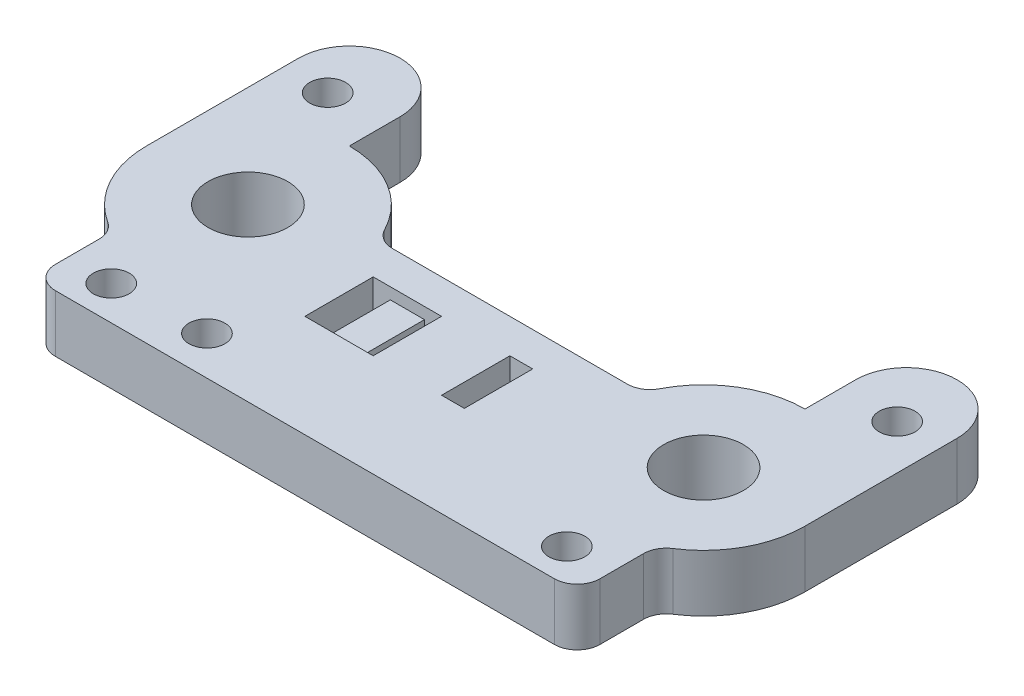
from build123d import *

# Parameters (mm, degrees)
BOSS_EXTRUDE1_DEPTH = 6.35
SKETCH3_R           = 4.445
CUT_EXTRUDE2_DEPTH  = 6.35
SKETCH11_W          = 2.54
SKETCH11_H          = 7.62
SKETCH11_W_2        = 1.905
CUT_EXTRUDE6_DEPTH  = 6.35
SKETCH14_W          = 3.81
SKETCH14_H          = 7.62
CUT_EXTRUDE8_DEPTH  = 1.27
SKETCH8_R           = 2
CUT_EXTRUDE10_DEPTH = 6.35
SKETCH15_R          = 2
CUT_EXTRUDE11_DEPTH = 6.35


with BuildPart() as part:
    # Sketch1 → Boss-Extrude1 (new body)
    with BuildSketch(Plane(origin=(0, 0, 0), x_dir=(1, 0, 0), z_dir=(0, 1, 0))):
        with BuildLine():
            Line((-25.4, 11.309999986), (-25.4, 16.964999979))
            ThreePointArc((-25.4, 16.964999979), (-31.054999993, 22.619999972), (-36.709999986, 16.964999979))
            Line((-36.709999986, 16.964999979), (-36.709999986, 11.309999986))
            Line((-36.709999986, 11.309999986), (-36.709999986, 0))
            ThreePointArc((-36.709999986, 0), (-35.329369206, -5.415138673), (-31.524548724, -9.508207119))
            ThreePointArc((-31.524548724, -9.508207119), (-30.670062071, -10.427428504), (-30.359999986, -11.643560444))
            Line((-30.359999986, -11.643560444), (-30.359999986, -16.51))
            ThreePointArc((-30.359999986, -16.51), (-29.61605121, -18.306051224), (-27.819999986, -19.05))
            Line((-27.819999986, -19.05), (27.819999986, -19.05))
            ThreePointArc((27.819999986, -19.05), (29.61605121, -18.306051224), (30.359999986, -16.51))
            Line((30.359999986, -16.51), (30.359999986, -11.643560444))
            ThreePointArc((30.359999986, -11.643560444), (30.670062071, -10.427428504), (31.524548724, -9.508207119))
            ThreePointArc((31.524548724, -9.508207119), (35.329369206, -5.415138673), (36.709999986, 0))
            Line((36.709999986, 0), (36.709999986, 11.309999986))
            Line((36.709999986, 11.309999986), (36.709999986, 16.964999979))
            ThreePointArc((36.709999986, 16.964999979), (31.054999993, 22.619999972), (25.4, 16.964999979))
            Line((25.4, 16.964999979), (25.4, 11.309999986))
            ThreePointArc((25.4, 11.309999986), (20.457539197, 10.172914081), (16.508889627, 6.990297277))
            ThreePointArc((16.508889627, 6.990297277), (15.885935778, 6.115446153), (15.348771474, 5.185451262))
            ThreePointArc((15.348771474, 5.185451262), (14.413140747, 4.180950232), (13.091466391, 3.81))
            Line((13.091466391, 3.81), (-13.091466391, 3.81))
            ThreePointArc((-13.091466391, 3.81), (-14.413140747, 4.180950232), (-15.348771474, 5.185451262))
            ThreePointArc((-15.348771474, 5.185451262), (-15.885935775, 6.115446149), (-16.508889621, 6.990297269))
            ThreePointArc((-16.508889621, 6.990297269), (-20.457539193, 10.172914079), (-25.4, 11.309999986))
        make_face()
    extrude(amount=BOSS_EXTRUDE1_DEPTH)

    # Sketch3 → Cut-Extrude2 (cut)
    with BuildSketch(Plane(origin=(0, 6.35, 0), x_dir=(1, 0, 0), z_dir=(0, 1, 0))):
        with Locations((-25.4, 0)):
            Circle(SKETCH3_R)
        with Locations((25.4, 0)):
            Circle(SKETCH3_R)
    extrude(amount=-CUT_EXTRUDE2_DEPTH, mode=Mode.SUBTRACT)

    # Sketch11 → Cut-Extrude6 (cut)
    with BuildSketch(Plane(origin=(0, 6.35, 0), x_dir=(1, 0, 0), z_dir=(0, 1, 0))):
        with Locations((5.08, -3.81)):
            Rectangle(SKETCH11_W, SKETCH11_H)
        with Locations((-4.7625, -3.81)):
            Rectangle(SKETCH11_W_2, SKETCH11_H)
        with Locations((-10.4775, -3.81)):
            Rectangle(SKETCH11_W_2, SKETCH11_H)
    extrude(amount=-CUT_EXTRUDE6_DEPTH, mode=Mode.SUBTRACT)

    # Sketch14 → Cut-Extrude8 (cut)
    with BuildSketch(Plane(origin=(0, 6.35, 0), x_dir=(1, 0, 0), z_dir=(0, 1, 0))):
        with Locations((-7.62, -3.81)):
            Rectangle(SKETCH14_W, SKETCH14_H)
    extrude(amount=-CUT_EXTRUDE8_DEPTH, mode=Mode.SUBTRACT)

    # Sketch8 → Cut-Extrude10 (cut)
    with BuildSketch(Plane(origin=(0, 6.35, 0), x_dir=(1, 0, 0), z_dir=(0, 1, 0))):
        with Locations((-31.75, 15.24)):
            Circle(SKETCH8_R)
        with Locations((25.4, -15.24)):
            Circle(SKETCH8_R)
        with Locations((-25.4, -15.24)):
            Circle(SKETCH8_R)
        with Locations((31.75, 15.24)):
            Circle(SKETCH8_R)
    extrude(amount=-CUT_EXTRUDE10_DEPTH, mode=Mode.SUBTRACT)

    # Sketch15 → Cut-Extrude11 (cut)
    with BuildSketch(Plane(origin=(0, 6.35, 0), x_dir=(1, 0, 0), z_dir=(0, 1, 0))):
        with Locations((-15.24, -14.732)):
            Circle(SKETCH15_R)
    extrude(amount=-CUT_EXTRUDE11_DEPTH, mode=Mode.SUBTRACT)


solid = part.part
